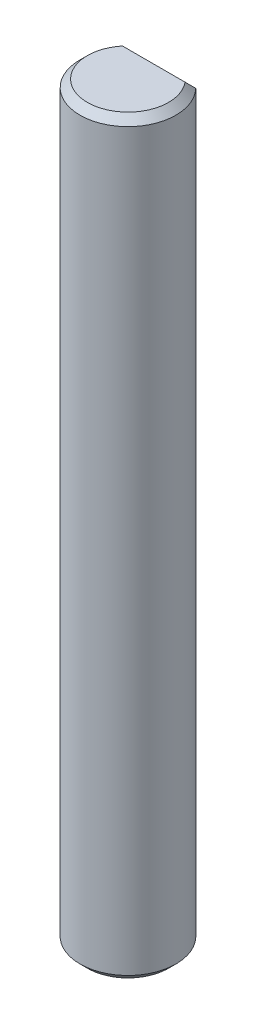
from build123d import *

# Parameters (mm, degrees)
BOSS_EXTRUDE1_DEPTH = 25.4
CHAMFER1_SIZE       = 0.5


with BuildPart() as part:
    # Sketch1 → Boss-Extrude1 (new body, symmetric)
    with BuildSketch(Plane(origin=(0, 0, 0), x_dir=(1, 0, 0), z_dir=(0, 1, 0))):
        with BuildLine():
            Line((-2.34520788, 2.25), (2.34520788, 2.25))
            ThreePointArc((2.34520788, 2.25), (0, -3.25), (-2.34520788, 2.25))
        make_face()
    extrude(amount=BOSS_EXTRUDE1_DEPTH, both=True)

    # Chamfer1
    chamfer1_edges = [part.edges().sort_by_distance(p)[0] for p in [
        (0, -25.4, -2.25),
        (0, -25.4, 3.25),
        (0, 25.4, 3.25),
        (0, 25.4, -2.25),
    ]]
    chamfer(chamfer1_edges, length=CHAMFER1_SIZE)


solid = part.part
